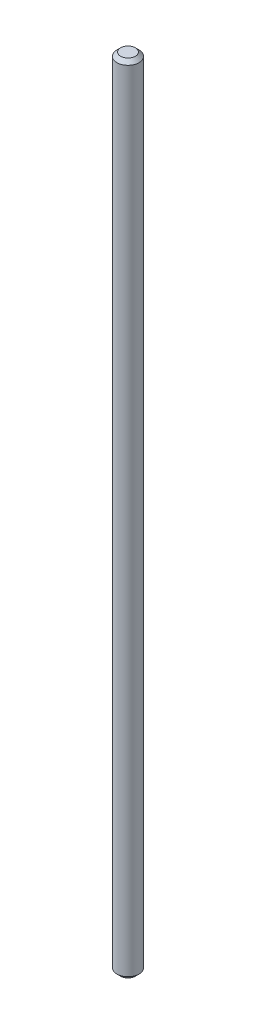
from build123d import *

# Parameters (mm, degrees)
CROQUIS1_R              = 1.5
SALIENTE_EXTRUIR1_DEPTH = 108
CHAFL_N1_SIZE           = 0.5


with BuildPart() as part:
    # Croquis1 → Saliente-Extruir1 (new body)
    with BuildSketch(Plane(origin=(0, 0, 0), x_dir=(1, 0, 0), z_dir=(0, 1, 0))):
        Circle(CROQUIS1_R)
    extrude(amount=SALIENTE_EXTRUIR1_DEPTH)

    # Chaflán1
    chafl_n1_edges = [part.edges().sort_by_distance(p)[0] for p in [
        (-1.5, 0, 0),
        (-1.5, 108, 0),
    ]]
    chamfer(chafl_n1_edges, length=CHAFL_N1_SIZE)


solid = part.part
